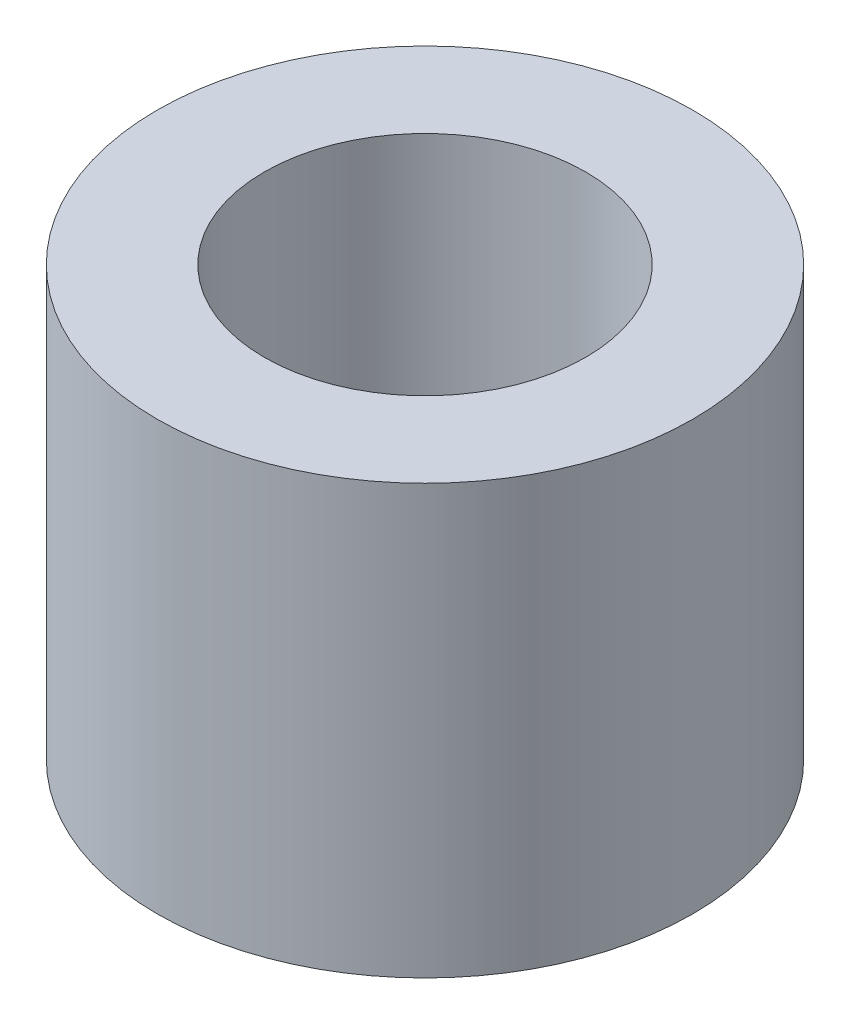
from build123d import *

# Parameters (mm, degrees)
SKETCH1_R           = 3.175
SKETCH1_R_2         = 1.905
BOSS_EXTRUDE1_DEPTH = 5.08


with BuildPart() as part:
    # Sketch1 → Boss-Extrude1 (new body)
    with BuildSketch(Plane(origin=(0, 0, 0), x_dir=(1, 0, 0), z_dir=(0, 1, 0))):
        Circle(SKETCH1_R)
        Circle(SKETCH1_R_2, mode=Mode.SUBTRACT)
    extrude(amount=BOSS_EXTRUDE1_DEPTH)


solid = part.part
